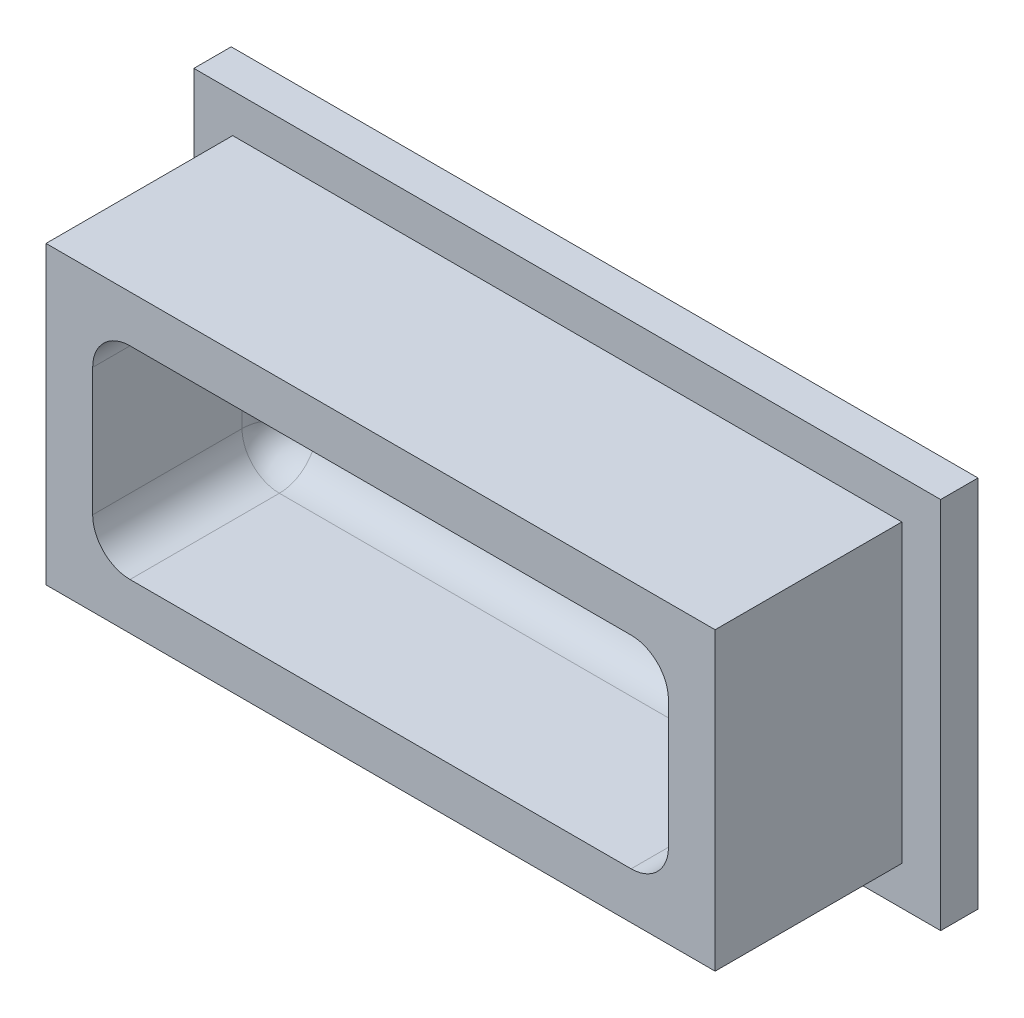
from build123d import *

# Parameters (mm, degrees)
SKETCH1_W           = 40
SKETCH1_H           = 20
BOSS_EXTRUDE1_DEPTH = 2
SKETCH2_W           = 35.84
SKETCH2_H           = 15.84
BOSS_EXTRUDE2_DEPTH = 10
SKETCH4_W           = 30.84
SKETCH4_H           = 10.84
CUT_EXTRUDE1_DEPTH  = 10
FILLET1_R           = 2


with BuildPart() as part:
    # Sketch1 → Boss-Extrude1 (new body)
    with BuildSketch(Plane.XY):
        Rectangle(SKETCH1_W, SKETCH1_H)
    extrude(amount=BOSS_EXTRUDE1_DEPTH)

    # Sketch2 → Boss-Extrude2 (add)
    with BuildSketch(Plane.XY.offset(2)):
        Rectangle(SKETCH2_W, SKETCH2_H)
    extrude(amount=BOSS_EXTRUDE2_DEPTH)

    # Sketch4 → Cut-Extrude1 (cut)
    with BuildSketch(Plane.XY.offset(12)):
        Rectangle(SKETCH4_W, SKETCH4_H)
    extrude(amount=-CUT_EXTRUDE1_DEPTH, mode=Mode.SUBTRACT)

    # Fillet1
    fillet1_edges = [part.edges().sort_by_distance(p)[0] for p in [
        (-15.42, 0, 2),
        (-15.42, -5.42, 7),
        (0, -5.42, 2),
        (15.42, -5.42, 7),
        (15.42, 0, 2),
        (15.42, 5.42, 7),
        (0, 5.42, 2),
        (-15.42, 5.42, 7),
    ]]
    fillet(fillet1_edges, radius=FILLET1_R)


solid = part.part
